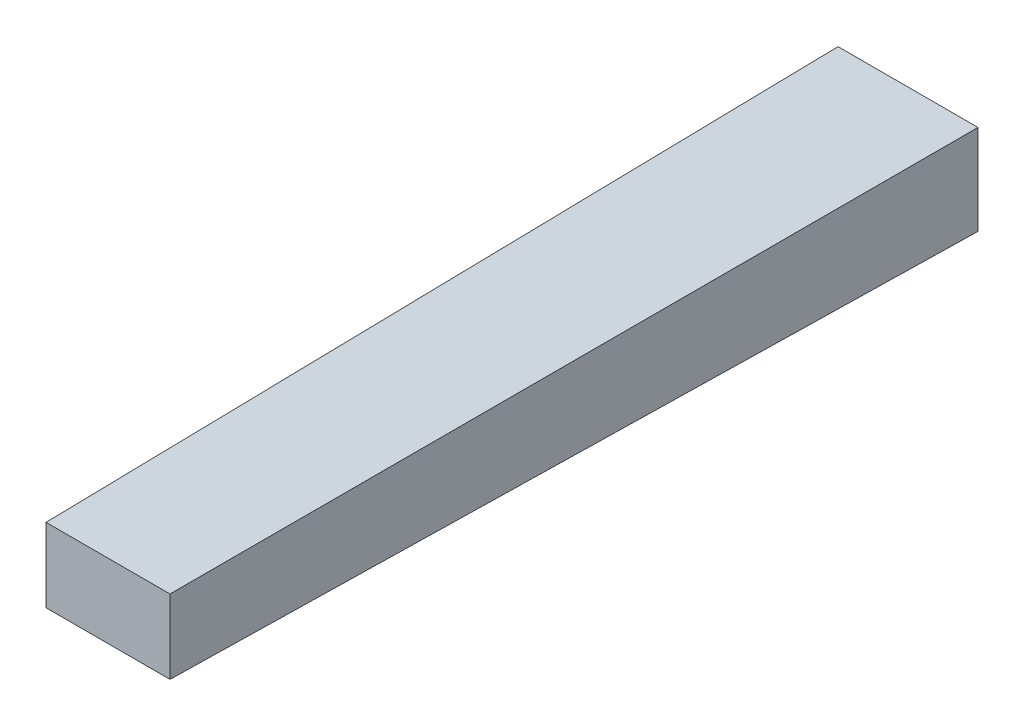
from build123d import *

# Parameters (mm, degrees)
SKETCH2_W           = 14
SKETCH2_H           = 9
BOSS_EXTRUDE1_DEPTH = 80
BOSS_EXTRUDE1_TAPER = 0.573


with BuildPart() as part:
    # Sketch2 → Boss-Extrude1 (new body)
    with BuildSketch(Plane.XY):
        with Locations((7, 4.5)):
            Rectangle(SKETCH2_W, SKETCH2_H)
    extrude(amount=BOSS_EXTRUDE1_DEPTH, taper=BOSS_EXTRUDE1_TAPER)


solid = part.part
